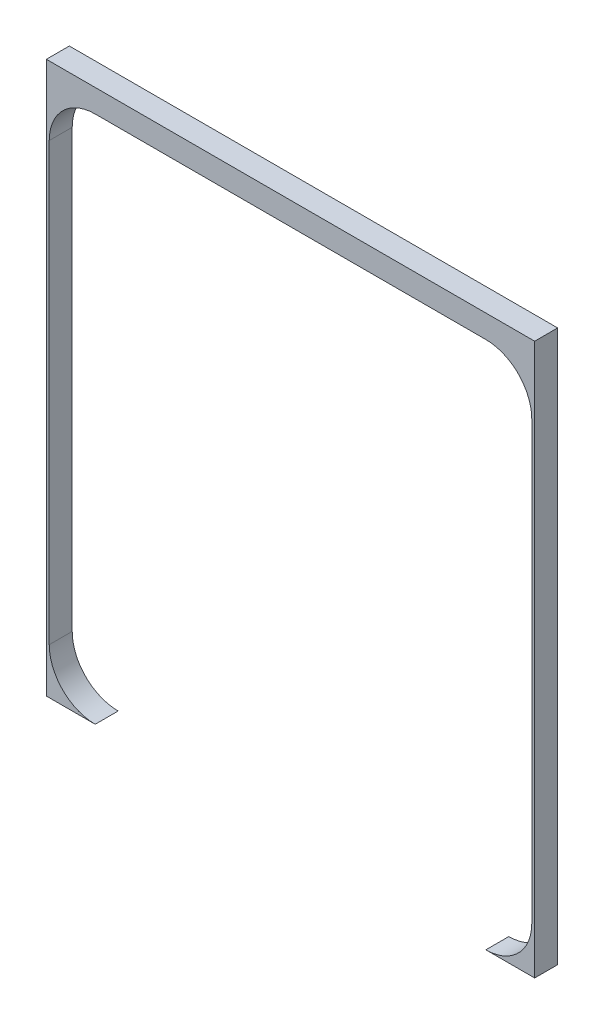
from build123d import *

# Parameters (mm, degrees)
SKETCH1_W           = 539.75
SKETCH1_H           = 609.6
BOSS_EXTRUDE1_DEPTH = 25.4
CUT_EXTRUDE1_DEPTH  = 26.4


with BuildPart() as part:
    # Sketch1 → Boss-Extrude1 (new body)
    with BuildSketch(Plane.XY):
        Rectangle(SKETCH1_W, SKETCH1_H)
    extrude(amount=BOSS_EXTRUDE1_DEPTH)

    # Sketch2 → Cut-Extrude1 (cut, through all)
    with BuildSketch(Plane(origin=(0, 0, 0), x_dir=(-1, 0, 0), z_dir=(0, 0, -1))):
        with BuildLine():
            Line((-266.7, -254), (-266.7, 228.6))
            ThreePointArc((-266.7, 228.6), (-251.821024484, 264.521024484), (-215.9, 279.4))
            Line((-215.9, 279.4), (215.9, 279.4))
            ThreePointArc((215.9, 279.4), (251.821024484, 264.521024484), (266.7, 228.6))
            Line((266.7, 228.6), (266.7, -254))
            ThreePointArc((266.7, -254), (251.821024484, -289.921024484), (215.9, -304.8))
            Line((215.9, -304.8), (-215.9, -304.8))
            ThreePointArc((-215.9, -304.8), (-251.821024484, -289.921024484), (-266.7, -254))
        make_face()
    extrude(amount=-CUT_EXTRUDE1_DEPTH, mode=Mode.SUBTRACT)


solid = part.part
